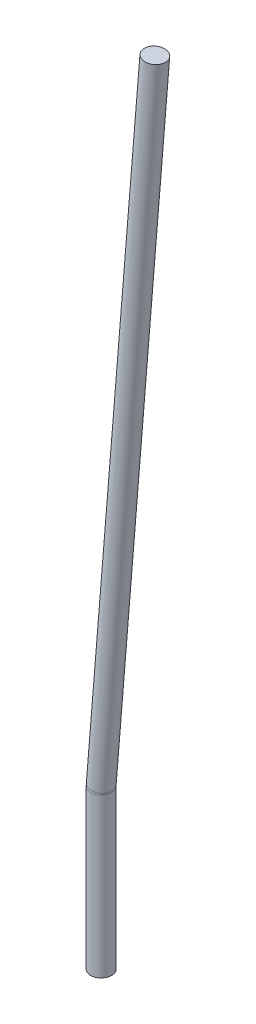
from build123d import *

# Parameters (mm, degrees)
SKETCH1_R           = 0.2
BOSS_EXTRUDE1_DEPTH = 3
SKETCH2_R           = 0.2
REVOLVE1_ANGLE      = 4.66
SKETCH3_R           = 0.2
BOSS_EXTRUDE2_DEPTH = 12.5


with BuildPart() as part:
    # Sketch1 → Boss-Extrude1 (new body)
    with BuildSketch(Plane(origin=(0, 0, 0), x_dir=(1, 0, 0), z_dir=(0, 1, 0))):
        Circle(SKETCH1_R)
    extrude(amount=-BOSS_EXTRUDE1_DEPTH)

    # Sketch2 → Revolve1 (revolve)
    with BuildSketch(Plane(origin=(0, 0, 0), x_dir=(1, 0, 0), z_dir=(0, 1, 0))):
        Circle(SKETCH2_R)
    revolve(axis=Axis((0.5, 0, -0.2), (0, 0, -1)), revolution_arc=REVOLVE1_ANGLE)

    # Sketch3 → Boss-Extrude2 (add)
    with BuildSketch(Plane(origin=(0.003300189, 0.040487072, 0), x_dir=(0.996694348, -0.081242705, 0), z_dir=(0.081242705, 0.996694348, 0))):
        with Locations((-0.001652826, 0)):
            Circle(SKETCH3_R)
    extrude(amount=BOSS_EXTRUDE2_DEPTH)


solid = part.part
